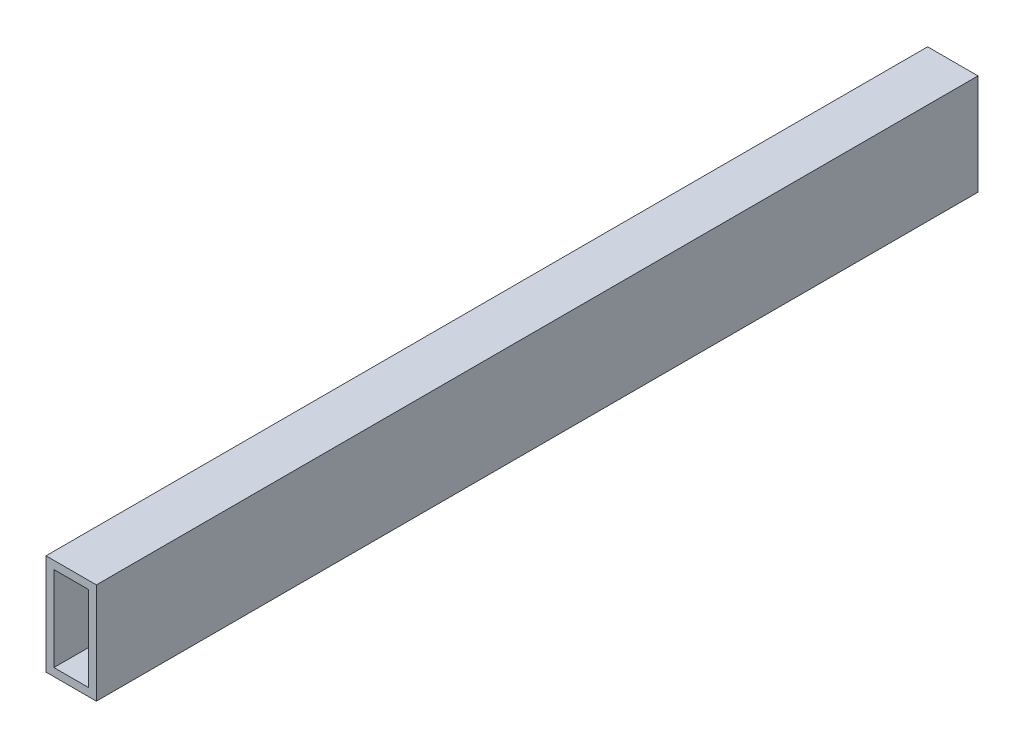
from build123d import *

# Parameters (mm, degrees)
SKETCH1_W   = 40
SKETCH1_H   = 80
SKETCH1_W_2 = 27.4
SKETCH1_H_2 = 67.4


with BuildPart() as part:
    # Sweep1: sweep along a curve in space
    with BuildLine() as sweep1_path:
        add(Edge.make_bspline(
            [(0, 0, -350), (0, 0, 350)],
            knots=[0, 0, 1, 1], degree=1))
    # Sketch1 → Sweep1 (sweep)
    with BuildSketch(Plane.XY):
        Rectangle(SKETCH1_W, SKETCH1_H)
        Rectangle(SKETCH1_W_2, SKETCH1_H_2, mode=Mode.SUBTRACT)
    sweep(path=sweep1_path.line)


solid = part.part
